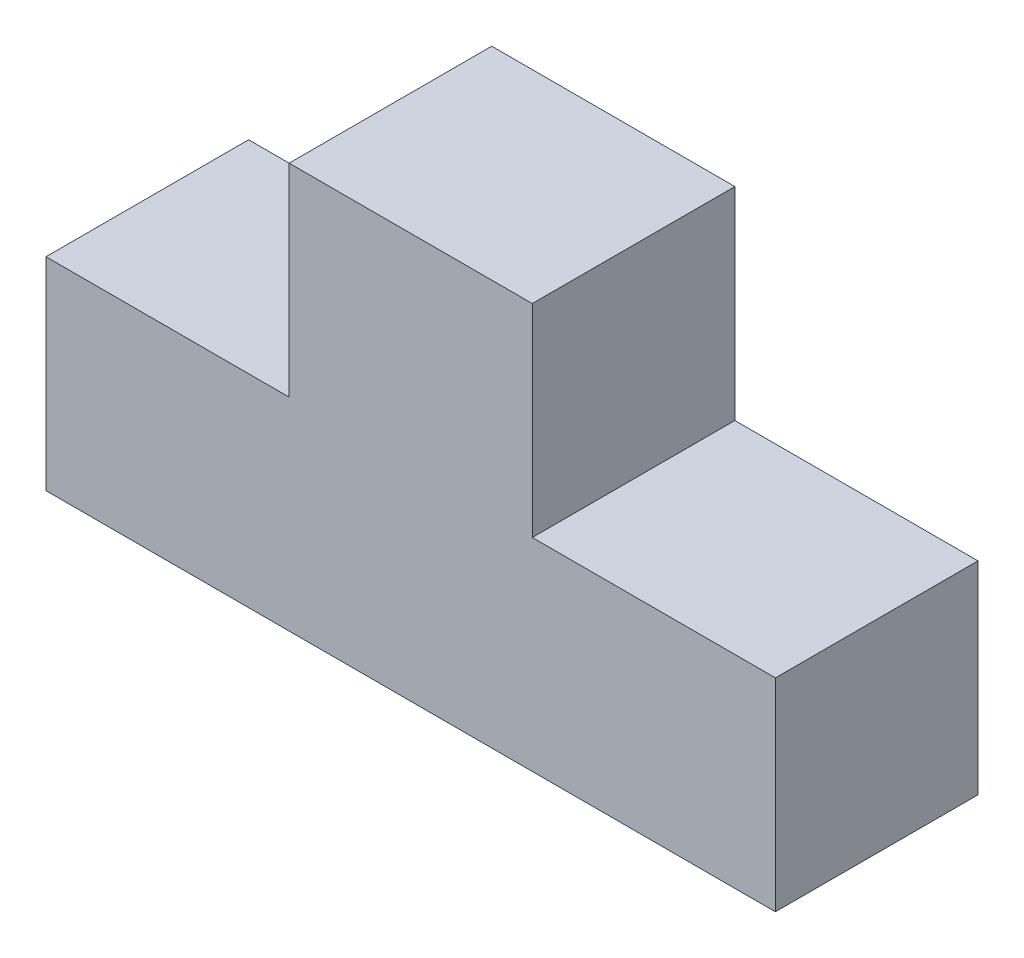
from build123d import *

# Parameters (mm, degrees)
BOSS_EXTRUDE1_DEPTH = 25


with BuildPart() as part:
    # Sketch1 → Boss-Extrude1 (new body)
    with BuildSketch(Plane.XY):
        Polygon((0, 0), (90, 0), (90, 25), (60, 25), (60, 50), (30, 50), (30, 25), (0, 25), align=None)
    extrude(amount=BOSS_EXTRUDE1_DEPTH)


solid = part.part
